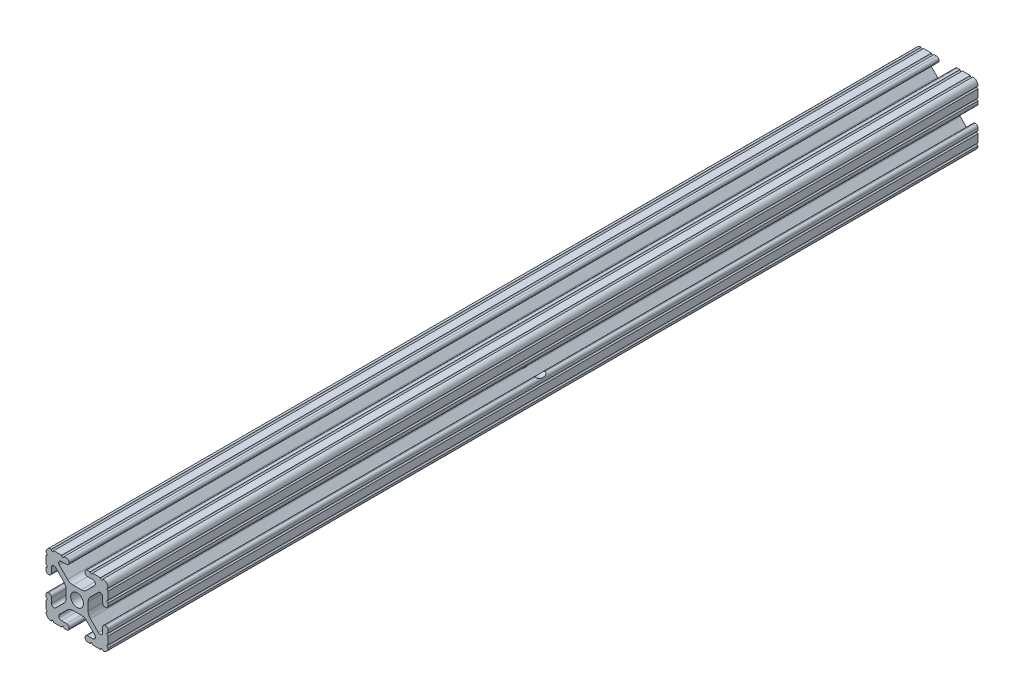
from build123d import *

# Parameters (mm, degrees)
SKETCH1_R               = 2.6035
BOSS_EXTRUDE1_DEPTH     = 177.8
SKETCH2_R               = 3.81
CUT_EXTRUDE1_DEPTH      = 25.4
SKETCH3_R               = 3.175
CUT_EXTRUDE2_DEPTH      = 180.080500267
CUT_EXTRUDE2_DEPTH_BACK = 180.080500267


with BuildPart() as part:
    # Sketch1 → Boss-Extrude1 (new, symmetric)
    with BuildSketch(Plane.XY):
        with BuildLine():
            Line((-7.179650497, -8.645192506), (-3.952270251, -5.423690499))
            ThreePointArc((-3.952270251, -5.423690499), (-2.922936451, -4.736929036), (-1.709253557, -4.4958))
            Line((-1.709253557, -4.4958), (1.709253557, -4.4958))
            ThreePointArc((1.709253557, -4.4958), (2.922936451, -4.736929036), (3.952270251, -5.423690499))
            Line((3.952270251, -5.423690499), (7.179650497, -8.645192506))
            ThreePointArc((7.179650497, -8.645192506), (7.41473083, -9.822813117), (6.416408329, -10.4902))
            Line((6.416408329, -10.4902), (4.287512407, -10.4902))
            ThreePointArc((4.287512407, -10.4902), (3.54574862, -10.79744862), (3.2385, -11.539212407))
            Line((3.2385, -11.539212407), (3.2385, -11.650987593))
            ThreePointArc((3.2385, -11.650987593), (3.54574862, -12.39275138), (4.287512407, -12.7))
            Line((4.287512407, -12.7), (5.317126718, -12.7))
            ThreePointArc((5.317126718, -12.7), (5.825126718, -12.192), (6.333126718, -12.7))
            Line((6.333126718, -12.7), (9.550443118, -12.7))
            ThreePointArc((9.550443118, -12.7), (10.058366869, -12.192000006), (10.566443095, -12.699847501))
            ThreePointArc((10.566443095, -12.699847501), (12.082537762, -12.08250727), (12.699846982, -10.566399977))
            ThreePointArc((12.699846982, -10.566399977), (12.192000006, -10.058323491), (12.7, -9.5504))
            Line((12.7, -9.5504), (12.7, -6.3330836))
            ThreePointArc((12.7, -6.3330836), (12.192, -5.8250836), (12.7, -5.3170836))
            Line((12.7, -5.3170836), (12.7, -4.287469289))
            ThreePointArc((12.7, -4.287469289), (12.39275138, -3.545705502), (11.650987593, -3.238456882))
            Line((11.650987593, -3.238456882), (11.539212407, -3.238456882))
            ThreePointArc((11.539212407, -3.238456882), (10.79744862, -3.545705502), (10.4902, -4.287469289))
            Line((10.4902, -4.287469289), (10.4902, -6.402089023))
            ThreePointArc((10.4902, -6.402089023), (9.856505071, -7.351067942), (8.737131347, -7.129408934))
            Line((8.737131347, -7.129408934), (5.441005833, -3.840816462))
            ThreePointArc((5.441005833, -3.840816462), (4.750877967, -2.809883091), (4.5085, -1.593185507))
            Line((4.5085, -1.593185507), (4.5085, 1.593185507))
            ThreePointArc((4.5085, 1.593185507), (4.750877967, 2.809883091), (5.441005833, 3.840816462))
            Line((5.441005833, 3.840816462), (8.737131347, 7.129408934))
            ThreePointArc((8.737131347, 7.129408934), (9.856505071, 7.351067942), (10.4902, 6.402089023))
            Line((10.4902, 6.402089023), (10.4902, 4.287469289))
            ThreePointArc((10.4902, 4.287469289), (10.79744862, 3.545705502), (11.539212407, 3.238456882))
            Line((11.539212407, 3.238456882), (11.650987593, 3.238456882))
            ThreePointArc((11.650987593, 3.238456882), (12.39275138, 3.545705502), (12.7, 4.287469289))
            Line((12.7, 4.287469289), (12.7, 5.3170836))
            ThreePointArc((12.7, 5.3170836), (12.192, 5.8250836), (12.7, 6.3330836))
            Line((12.7, 6.3330836), (12.7, 9.5504))
            ThreePointArc((12.7, 9.5504), (12.192000006, 10.058323491), (12.699846982, 10.566399977))
            ThreePointArc((12.699846982, 10.566399977), (12.082537762, 12.08250727), (10.566443095, 12.699847501))
            ThreePointArc((10.566443095, 12.699847501), (10.058366869, 12.192000006), (9.550443118, 12.7))
            Line((9.550443118, 12.7), (6.333126718, 12.7))
            ThreePointArc((6.333126718, 12.7), (5.825126718, 12.192), (5.317126718, 12.7))
            Line((5.317126718, 12.7), (4.287512407, 12.7))
            ThreePointArc((4.287512407, 12.7), (3.54574862, 12.39275138), (3.2385, 11.650987593))
            Line((3.2385, 11.650987593), (3.2385, 11.539212407))
            ThreePointArc((3.2385, 11.539212407), (3.54574862, 10.79744862), (4.287512407, 10.4902))
            Line((4.287512407, 10.4902), (6.476788598, 10.4902))
            ThreePointArc((6.476788598, 10.4902), (7.432222385, 9.85140422), (7.207036008, 8.724370562))
            Line((7.207036008, 8.724370562), (3.898272566, 5.423169045))
            ThreePointArc((3.898272566, 5.423169045), (2.869120213, 4.736787962), (1.655778399, 4.4958))
            Line((1.655778399, 4.4958), (-1.655778399, 4.4958))
            ThreePointArc((-1.655778399, 4.4958), (-2.869120213, 4.736787962), (-3.898272566, 5.423169045))
            Line((-3.898272566, 5.423169045), (-7.207036008, 8.724370562))
            ThreePointArc((-7.207036008, 8.724370562), (-7.432222385, 9.85140422), (-6.476788598, 10.4902))
            Line((-6.476788598, 10.4902), (-4.287512407, 10.4902))
            ThreePointArc((-4.287512407, 10.4902), (-3.54574862, 10.79744862), (-3.2385, 11.539212407))
            Line((-3.2385, 11.539212407), (-3.2385, 11.650987593))
            ThreePointArc((-3.2385, 11.650987593), (-3.54574862, 12.39275138), (-4.287512407, 12.7))
            Line((-4.287512407, 12.7), (-5.317126718, 12.7))
            ThreePointArc((-5.317126718, 12.7), (-5.825126718, 12.192), (-6.333126718, 12.7))
            Line((-6.333126718, 12.7), (-9.550443118, 12.7))
            ThreePointArc((-9.550443118, 12.7), (-10.058366869, 12.192000006), (-10.566443095, 12.699847501))
            ThreePointArc((-10.566443095, 12.699847501), (-12.082537762, 12.08250727), (-12.699846982, 10.566399977))
            ThreePointArc((-12.699846982, 10.566399977), (-12.192000006, 10.058323491), (-12.7, 9.5504))
            Line((-12.7, 9.5504), (-12.7, 6.3330836))
            ThreePointArc((-12.7, 6.3330836), (-12.192, 5.8250836), (-12.7, 5.3170836))
            Line((-12.7, 5.3170836), (-12.7, 4.287469289))
            ThreePointArc((-12.7, 4.287469289), (-12.39275138, 3.545705502), (-11.650987593, 3.238456882))
            Line((-11.650987593, 3.238456882), (-11.539212407, 3.238456882))
            ThreePointArc((-11.539212407, 3.238456882), (-10.79744862, 3.545705502), (-10.4902, 4.287469289))
            Line((-10.4902, 4.287469289), (-10.4902, 6.402089023))
            ThreePointArc((-10.4902, 6.402089023), (-9.856505071, 7.351067942), (-8.737131347, 7.129408934))
            Line((-8.737131347, 7.129408934), (-5.441005833, 3.840816462))
            ThreePointArc((-5.441005833, 3.840816462), (-4.750877967, 2.809883091), (-4.5085, 1.593185507))
            Line((-4.5085, 1.593185507), (-4.5085, -1.593185507))
            ThreePointArc((-4.5085, -1.593185507), (-4.750877967, -2.809883091), (-5.441005833, -3.840816462))
            Line((-5.441005833, -3.840816462), (-8.737131347, -7.129408934))
            ThreePointArc((-8.737131347, -7.129408934), (-9.856505071, -7.351067942), (-10.4902, -6.402089023))
            Line((-10.4902, -6.402089023), (-10.4902, -4.287469289))
            ThreePointArc((-10.4902, -4.287469289), (-10.79744862, -3.545705502), (-11.539212407, -3.238456882))
            Line((-11.539212407, -3.238456882), (-11.650987593, -3.238456882))
            ThreePointArc((-11.650987593, -3.238456882), (-12.39275138, -3.545705502), (-12.7, -4.287469289))
            Line((-12.7, -4.287469289), (-12.7, -5.3170836))
            ThreePointArc((-12.7, -5.3170836), (-12.192, -5.8250836), (-12.7, -6.3330836))
            Line((-12.7, -6.3330836), (-12.7, -9.5504))
            ThreePointArc((-12.7, -9.5504), (-12.192000006, -10.058323491), (-12.699846982, -10.566399977))
            ThreePointArc((-12.699846982, -10.566399977), (-12.082537762, -12.08250727), (-10.566443095, -12.699847501))
            ThreePointArc((-10.566443095, -12.699847501), (-10.058366869, -12.192000006), (-9.550443118, -12.7))
            Line((-9.550443118, -12.7), (-6.333126718, -12.7))
            ThreePointArc((-6.333126718, -12.7), (-5.825126718, -12.192), (-5.317126718, -12.7))
            Line((-5.317126718, -12.7), (-4.287512407, -12.7))
            ThreePointArc((-4.287512407, -12.7), (-3.54574862, -12.39275138), (-3.2385, -11.650987593))
            Line((-3.2385, -11.650987593), (-3.2385, -11.539212407))
            ThreePointArc((-3.2385, -11.539212407), (-3.54574862, -10.79744862), (-4.287512407, -10.4902))
            Line((-4.287512407, -10.4902), (-6.416408329, -10.4902))
            ThreePointArc((-6.416408329, -10.4902), (-7.41473083, -9.822813117), (-7.179650497, -8.645192506))
        make_face()
        Circle(SKETCH1_R, mode=Mode.SUBTRACT)
    extrude(amount=BOSS_EXTRUDE1_DEPTH, both=True)

    # Sketch2 → Cut-Extrude1 (cut)
    with BuildSketch(Plane.ZY.offset(12.7)):
        with Locations(Location((0, 0, 0), (0, 0, 24.718407228))):
            Circle(SKETCH2_R)
    extrude(amount=-CUT_EXTRUDE1_DEPTH, mode=Mode.SUBTRACT)

    # Sketch3 → Cut-Extrude2 (cut, two sides)
    with BuildSketch(Plane(origin=(0, 4.4958, 0), x_dir=(1, 0, 0), z_dir=(0, 1, 0))) as cut_extrude2_sk:
        with Locations(Location((0, -165.1, 0), (0, 0, 237.428778052))):
            Circle(SKETCH3_R)
        with Locations(Location((0, 165.1, 0), (0, 0, 237.428778052))):
            Circle(SKETCH3_R)
    extrude(amount=CUT_EXTRUDE2_DEPTH, mode=Mode.SUBTRACT)
    extrude(cut_extrude2_sk.sketch, amount=-CUT_EXTRUDE2_DEPTH_BACK, mode=Mode.SUBTRACT)


solid = part.part
